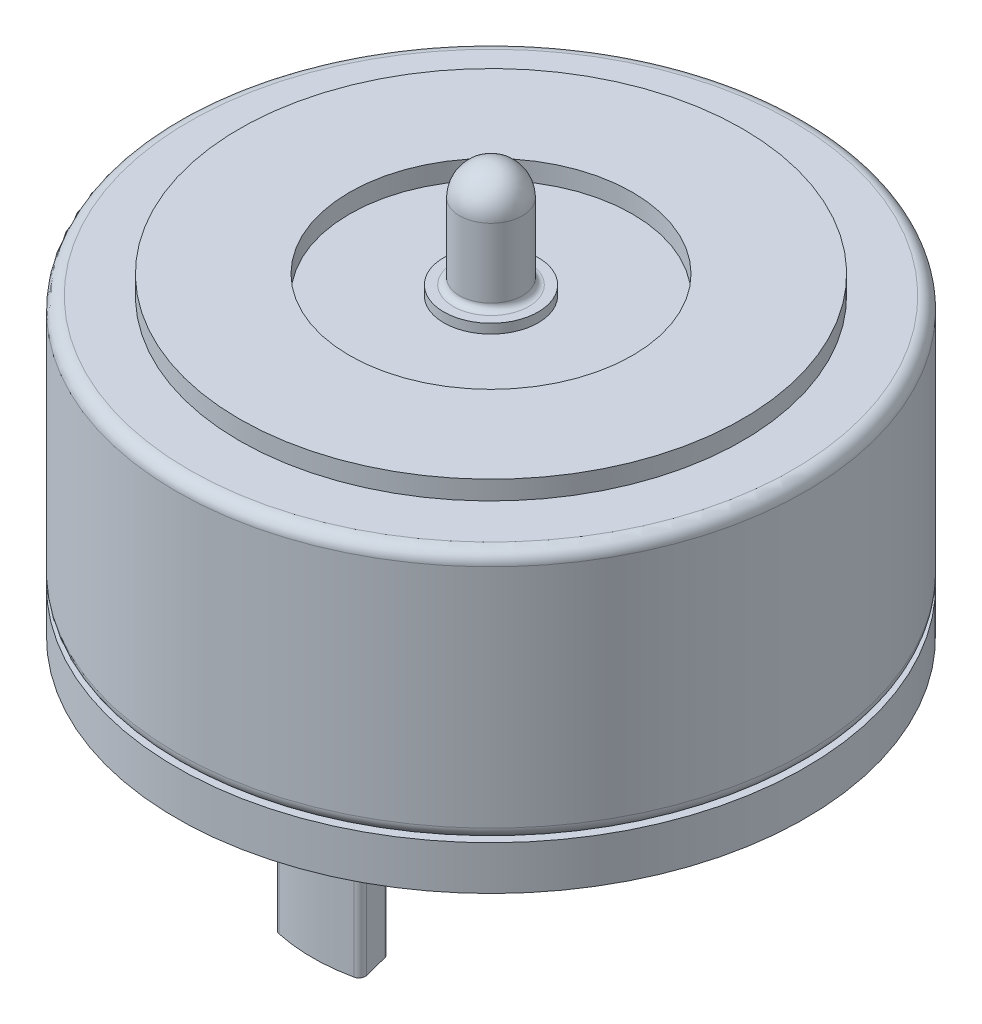
from build123d import *

# Parameters (mm, degrees)
SKETCH_1_R          = 5
EXTRUDE_1_DEPTH     = 4.3
SKETCH_2_R          = 5
SKETCH_2_R_2        = 4
SKETCH_2_R_3        = 2.25
CUT_EXTRUDE_1_DEPTH = 0.3
SKETCH_3_R          = 0.75
EXTRUDE_2_DEPTH     = 0.15
SKETCH_4_R          = 0.5
EXTRUDE_3_DEPTH     = 1.7
FILLET_1_R          = 0.5
FILLET_2_R          = 0.2
FILLET_3_R          = 0.1
SKETCH_5_R          = 5
EXTRUDE_4_DEPTH     = 0.7
EXTRUDE_5_DEPTH     = 3
FILLET_4_R          = 0.1
SKETCH_7_R          = 0.3
EXTRUDE_6_DEPTH     = 3


with BuildPart() as part:
    # Эскиз1 → Бобышка-Вытянуть1 (new body)
    with BuildSketch(Plane(origin=(0, 0, 0), x_dir=(1, 0, 0), z_dir=(0, 1, 0))):
        Circle(SKETCH_1_R)
    extrude(amount=EXTRUDE_1_DEPTH)

    # Эскиз2 → Вырез-Вытянуть1 (cut)
    with BuildSketch(Plane(origin=(0, 4.3, 0), x_dir=(1, 0, 0), z_dir=(0, 1, 0))):
        Circle(SKETCH_2_R)
        Circle(SKETCH_2_R_2, mode=Mode.SUBTRACT)
        Circle(SKETCH_2_R_3)
    extrude(amount=-CUT_EXTRUDE_1_DEPTH, mode=Mode.SUBTRACT)

    # Эскиз3 → Бобышка-Вытянуть2 (add)
    with BuildSketch(Plane(origin=(0, 4, 0), x_dir=(1, 0, 0), z_dir=(0, 1, 0))):
        Circle(SKETCH_3_R)
    extrude(amount=EXTRUDE_2_DEPTH)

    # Эскиз4 → Бобышка-Вытянуть3 (add)
    with BuildSketch(Plane(origin=(0, 4.15, 0), x_dir=(1, 0, 0), z_dir=(0, 1, 0))):
        Circle(SKETCH_4_R)
    extrude(amount=EXTRUDE_3_DEPTH)

    # Скругление1
    fillet_1_edges = [part.edges().sort_by_distance(p)[0] for p in [
        (-0.5, 5.85, 0),
    ]]
    fillet(fillet_1_edges, radius=FILLET_1_R)

    # Скругление2
    fillet_2_edges = [part.edges().sort_by_distance(p)[0] for p in [
        (-5, 0, 0),
        (-5, 4, 0),
    ]]
    fillet(fillet_2_edges, radius=FILLET_2_R)

    # Скругление3
    fillet_3_edges = [part.edges().sort_by_distance(p)[0] for p in [
        (-0.5, 4.15, 0),
    ]]
    fillet(fillet_3_edges, radius=FILLET_3_R)

    # Эскиз5 → Бобышка-Вытянуть4 (add)
    with BuildSketch(Plane.XZ):
        Circle(SKETCH_5_R)
    extrude(amount=EXTRUDE_4_DEPTH)

    # Эскиз6 → Бобышка-Вытянуть5 (add)
    with BuildSketch(Plane.XZ.offset(0.7)):
        with BuildLine():
            Line((0.7, 2.752380788), (0.552112676, 2.170891889))
            ThreePointArc((0.552112676, 2.170891889), (0, 2.24), (-0.552112676, 2.170891889))
            Line((-0.552112676, 2.170891889), (-0.7, 2.752380788))
            ThreePointArc((-0.7, 2.752380788), (0, 2.84), (0.7, 2.752380788))
        make_face()
        with BuildLine():
            Line((0.552112676, -2.170891889), (0.7, -2.752380788))
            ThreePointArc((0.7, -2.752380788), (0, -2.84), (-0.7, -2.752380788))
            Line((-0.7, -2.752380788), (-0.552112676, -2.170891889))
            ThreePointArc((-0.552112676, -2.170891889), (0, -2.24), (0.552112676, -2.170891889))
        make_face()
    extrude(amount=EXTRUDE_5_DEPTH)

    # Скругление4
    fillet_4_edges = [part.edges().sort_by_distance(p)[0] for p in [
        (0.7, -2.2, 2.752380788),
        (-0.7, -2.2, 2.752380788),
        (-0.552112676, -2.2, 2.170891889),
        (0.552112676, -2.2, 2.170891889),
        (-0.7, -2.2, -2.752380788),
        (0.7, -2.2, -2.752380788),
        (0.552112676, -2.2, -2.170891889),
        (-0.552112676, -2.2, -2.170891889),
    ]]
    fillet(fillet_4_edges, radius=FILLET_4_R)

    # Эскиз7 → Бобышка-Вытянуть6 (add)
    with BuildSketch(Plane.XZ.offset(0.7)):
        Circle(SKETCH_7_R)
    extrude(amount=EXTRUDE_6_DEPTH)


solid = part.part
